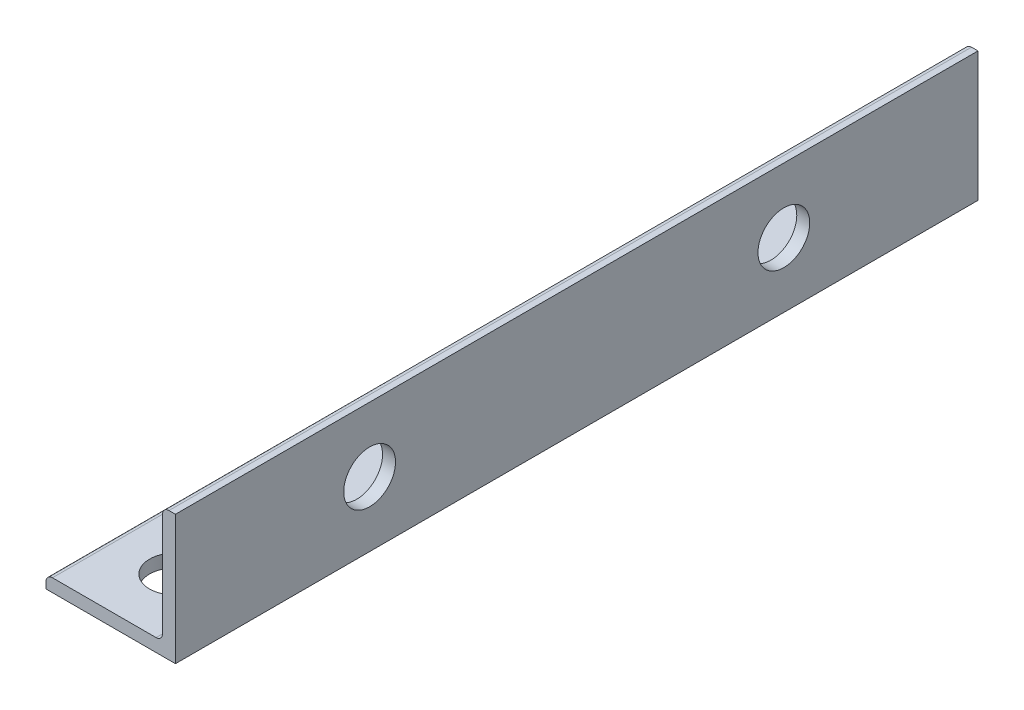
from build123d import *

# Parameters (mm, degrees)
BOSS_EXTRUDE1_DEPTH = 49.2125
SKETCH3_R           = 3.175
CUT_EXTRUDE1_DEPTH  = 16.875
CUT_EXTRUDE2_REACH  = 17.875
SKETCH4_R           = 3.175


with BuildPart() as part:
    # Sketch2 → Boss-Extrude1 (new body, symmetric)
    with BuildSketch(Plane.XY):
        with BuildLine():
            Line((-7.9375, 0), (7.9375, 0))
            Line((7.9375, 0), (7.9375, 15.875))
            Line((7.9375, 15.875), (7.14375, 15.875))
            ThreePointArc((7.14375, 15.875), (6.582483992, 15.642516008), (6.35, 15.08125))
            Line((6.35, 15.08125), (6.35, 2.38125))
            ThreePointArc((6.35, 2.38125), (6.117516008, 1.819983992), (5.55625, 1.5875))
            Line((5.55625, 1.5875), (-7.14375, 1.5875))
            ThreePointArc((-7.14375, 1.5875), (-7.705016008, 1.355016008), (-7.9375, 0.79375))
            Line((-7.9375, 0.79375), (-7.9375, 0))
        make_face()
    extrude(amount=BOSS_EXTRUDE1_DEPTH, both=True)

    # Sketch3 → Cut-Extrude1 (cut, through all)
    with BuildSketch(Plane(origin=(7.9375, 0, 0), x_dir=(0, 0, -1), z_dir=(1, 0, 0))):
        with Locations((-25.4, 7.9375)):
            Circle(SKETCH3_R)
        with Locations((25.4, 7.9375)):
            Circle(SKETCH3_R)
    extrude(amount=-CUT_EXTRUDE1_DEPTH, mode=Mode.SUBTRACT)

    # Sketch4 → Cut-Extrude2 (cut, up to next)
    with BuildSketch(Plane.XZ, mode=Mode.PRIVATE) as cut_extrude2_sk1:
        with Locations((0, -41.275)):
            Circle(SKETCH4_R)
    cut_extrude2_tool1 = extrude(cut_extrude2_sk1.sketch, amount=-CUT_EXTRUDE2_REACH, mode=Mode.PRIVATE) & part.part
    add(cut_extrude2_tool1.solids().sort_by_distance((0, 0, -41.275))[0], mode=Mode.SUBTRACT)
    # Sketch4 → Cut-Extrude2 (cut, up to next)
    with BuildSketch(Plane.XZ, mode=Mode.PRIVATE) as cut_extrude2_sk2:
        with Locations((0, 41.275)):
            Circle(SKETCH4_R)
    cut_extrude2_tool2 = extrude(cut_extrude2_sk2.sketch, amount=-CUT_EXTRUDE2_REACH, mode=Mode.PRIVATE) & part.part
    add(cut_extrude2_tool2.solids().sort_by_distance((0, 0, 41.275))[0], mode=Mode.SUBTRACT)


solid = part.part
